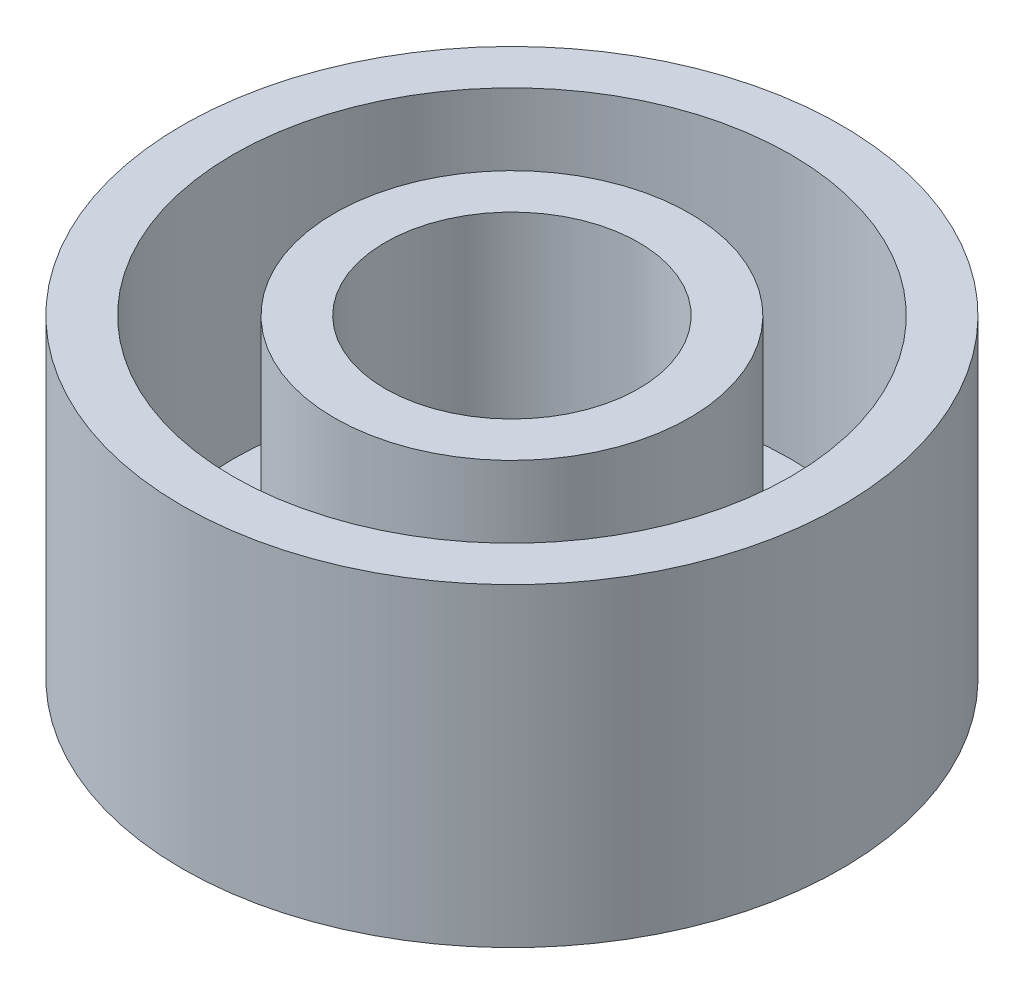
from build123d import *

# Parameters (mm, degrees)
SKETCH1_R               = 32.5
SKETCH1_R_2             = 27.5
BOSS_EXTRUDE2_DEPTH     = 26
SKETCH1_R_3             = 17.5
SKETCH1_R_4             = 12.5
BOSS_EXTRUDE2_2_DEPTH   = 26
SKETCH2_R               = 32.5
SKETCH2_R_2             = 8
BOSS_EXTRUDE3_DEPTH     = 5
SKETCH3_R               = 1.5
CUT_EXTRUDE1_DEPTH      = 3
CUT_EXTRUDE1_DEPTH_BACK = 6


with BuildPart() as part:
    # Sketch1 → Boss-Extrude2 (new body)
    with BuildSketch(Plane(origin=(0, 0, 0), x_dir=(1, 0, 0), z_dir=(0, 1, 0))):
        Circle(SKETCH1_R)
        Circle(SKETCH1_R_2, mode=Mode.SUBTRACT)
    extrude(amount=BOSS_EXTRUDE2_DEPTH)



with BuildPart() as body_2:
    # Sketch1 → Boss-Extrude2 2 (new body)
    with BuildSketch(Plane(origin=(0, 0, 0), x_dir=(1, 0, 0), z_dir=(0, 1, 0))):
        Circle(SKETCH1_R_3)
        Circle(SKETCH1_R_4, mode=Mode.SUBTRACT)
    extrude(amount=BOSS_EXTRUDE2_2_DEPTH)


with BuildPart() as part_1:
    add(part.part)

    add(body_2.part)  # Boss-Extrude3 merges body 2
    # Sketch2 → Boss-Extrude3 (add)
    with BuildSketch(Plane(origin=(0, 0, 0), x_dir=(1, 0, 0), z_dir=(0, 1, 0))):
        Circle(SKETCH2_R)
        Circle(SKETCH2_R_2, mode=Mode.SUBTRACT)
    extrude(amount=-BOSS_EXTRUDE3_DEPTH)

    # Sketch3 → Cut-Extrude1 (cut, two sides)
    with BuildSketch(Plane(origin=(0, 0, 0), x_dir=(1, 0, 0), z_dir=(0, 1, 0))) as cut_extrude1_sk:
        with Locations((-7.247844507, 7.247844507)):
            Circle(SKETCH3_R)
        with Locations((7.247844507, 7.247844507)):
            Circle(SKETCH3_R)
        with Locations((7.247844507, -7.247844507)):
            Circle(SKETCH3_R)
        with Locations((-7.247844507, -7.247844507)):
            Circle(SKETCH3_R)
    extrude(amount=CUT_EXTRUDE1_DEPTH, mode=Mode.SUBTRACT)
    extrude(cut_extrude1_sk.sketch, amount=-CUT_EXTRUDE1_DEPTH_BACK, mode=Mode.SUBTRACT)


solid = part_1.part
